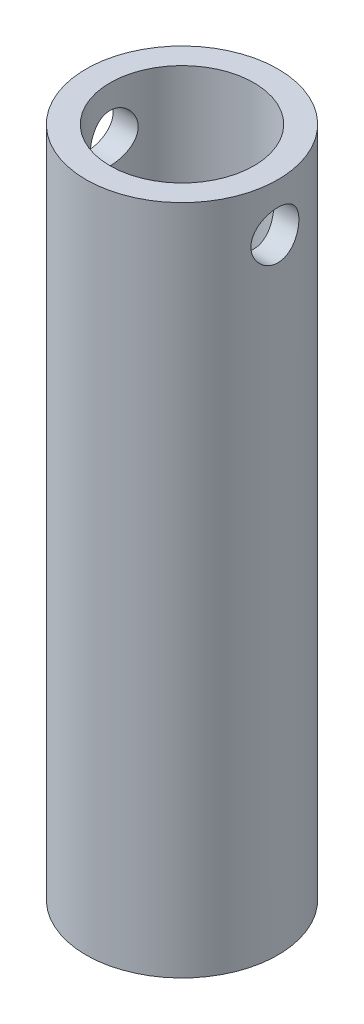
from build123d import *

# Parameters (mm, degrees)
SKETCH1_R               = 12.7
SKETCH1_R_2             = 9.525
BOSS_EXTRUDE1_DEPTH     = 88.9
SKETCH2_R               = 3.175
CUT_EXTRUDE1_DEPTH      = 13.7
CUT_EXTRUDE1_DEPTH_BACK = 13.7


with BuildPart() as part:
    # Sketch1 → Boss-Extrude1 (new body)
    with BuildSketch(Plane(origin=(0, 0, 0), x_dir=(1, 0, 0), z_dir=(0, 1, 0))):
        Circle(SKETCH1_R)
        Circle(SKETCH1_R_2, mode=Mode.SUBTRACT)
    extrude(amount=BOSS_EXTRUDE1_DEPTH)

    # Sketch2 → Cut-Extrude1 (cut, two sides)
    with BuildSketch(Plane(origin=(0, 0, 0), x_dir=(0, 0, -1), z_dir=(1, 0, 0))) as cut_extrude1_sk:
        with Locations((0, 82.55)):
            Circle(SKETCH2_R)
    extrude(amount=CUT_EXTRUDE1_DEPTH, mode=Mode.SUBTRACT)
    extrude(cut_extrude1_sk.sketch, amount=-CUT_EXTRUDE1_DEPTH_BACK, mode=Mode.SUBTRACT)


solid = part.part
